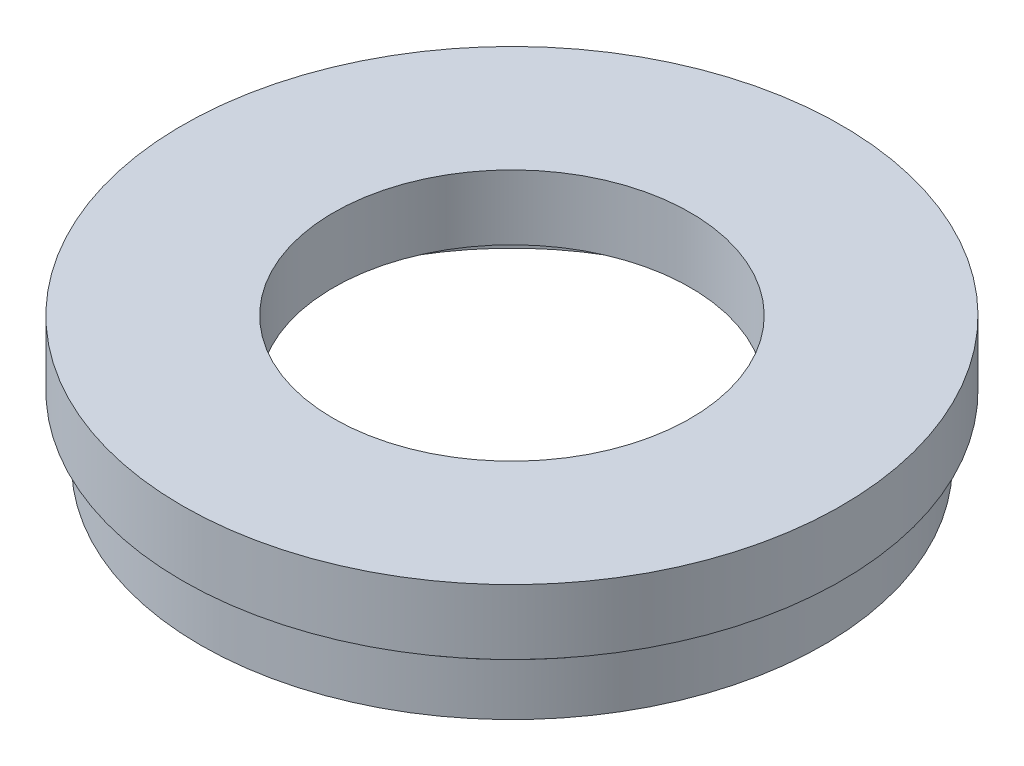
from build123d import *


with BuildPart() as part:
    # 草图1 → 旋转1 (revolve)
    with BuildSketch(Plane.XY, mode=Mode.PRIVATE) as revolve_1_sk:
        Polygon((20.5, 0), (20.5, 4), (21.1, 4), (21.1, 5), (13.75, 5), (13.75, 10), (25.4, 10), (25.4, 5), (23.5, 5), (23.5, 4), (24, 4), (24, 0), align=None)
    revolve(revolve_1_sk.sketch.rotate(Axis((0, 17.419298318, 0), (0, -1, 0)), 90), axis=Axis((0, 17.419298318, 0), (0, -1, 0)))  # turned: the seam where the file's is


solid = part.part
